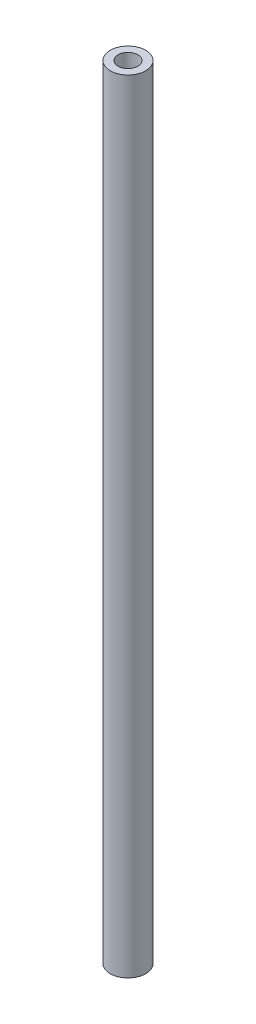
from build123d import *

# Parameters (mm, degrees)
SKETCH2_R           = 11.35
BOSS_EXTRUDE1_DEPTH = 500
HOLE2_D             = 12.7


with BuildPart() as part:
    # Sketch2 → Boss-Extrude1 (new body)
    with BuildSketch(Plane(origin=(0, 0, 0), x_dir=(1, 0, 0), z_dir=(0, 1, 0))):
        Circle(SKETCH2_R)
    extrude(amount=BOSS_EXTRUDE1_DEPTH)

    # Hole2 (through all)
    with Locations(Plane(origin=(0, 0, 0), x_dir=(-1, 0, 0), z_dir=(0, -1, 0))):
        with Locations((0, 0)):
            Hole(HOLE2_D / 2)


solid = part.part
